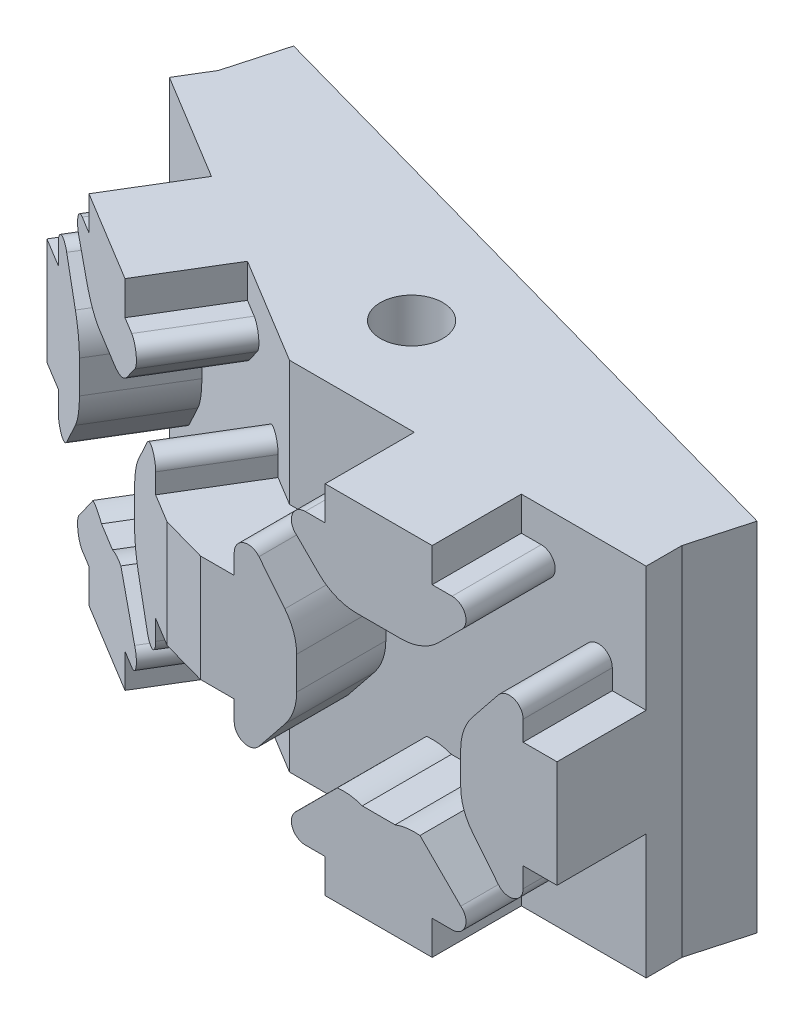
from build123d import *

# Parameters (mm, degrees)
SKIZZE1_W                       = 20
SKIZZE1_H                       = 20
AUFSATZ_LINEAR_AUSTRAGEN1_DEPTH = 2
AUFSATZ_LINEAR_AUSTRAGEN3_DEPTH = 5
VERRUNDUNG1_R                   = 3
VERRUNDUNG1_OF_SPIEGELN1_R      = 3
AUFSATZ_LINEAR_AUSTRAGEN4_REACH = 22.848
SKIZZE3_W                       = 37.447689889
SKIZZE3_H                       = 20
SKIZZE4_R                       = 1.75
SCHNITT_LINEAR_AUSTRAGEN1_DEPTH = 21
SKIZZE4_3_R                     = 2.9
SKIZZE4_3_R_2                   = 1.75
SCHNITT_LINEAR_AUSTRAGEN2_DEPTH = 16
AUFSATZ_LINEAR_AUSTRAGEN5_REACH = 27.254
SKIZZE5_W                       = 2.691263413
SKIZZE5_H                       = 6


with BuildPart() as part:
    # Skizze1 → Aufsatz-Linear austragen1 (new body)
    with BuildSketch(Plane.XY):
        with Locations((10, 10)):
            Rectangle(SKIZZE1_W, SKIZZE1_H)
    aufsatz_linear_austragen1 = extrude(amount=AUFSATZ_LINEAR_AUSTRAGEN1_DEPTH)

    # Skizze2 → Aufsatz-Linear austragen3 (add)
    with BuildSketch(Plane.XY.offset(2)):
        with BuildLine():
            Line((13, 18.1), (13, 20))
            Line((13, 20), (7, 20))
            Line((7, 20), (7, 18.1))
            Line((7, 18.1), (5.883086579, 18.1))
            ThreePointArc((5.883086579, 18.1), (5.147285539, 17.57883746), (5.394745881, 16.711786745))
            Line((5.394745881, 16.711786745), (7.506532626, 14.6))
            Line((7.506532626, 14.6), (9.080240322, 14.6))
            Line((9.080240322, 14.6), (10.919759678, 14.6))
            Line((10.919759678, 14.6), (12.493467374, 14.6))
            Line((12.493467374, 14.6), (14.605254119, 16.711786745))
            ThreePointArc((14.605254119, 16.711786745), (14.852714461, 17.57883746), (14.116913421, 18.1))
            Line((14.116913421, 18.1), (13, 18.1))
        make_face()
        with BuildLine():
            Line((1.9, 13), (0, 13))
            Line((0, 13), (0, 7))
            Line((0, 7), (1.9, 7))
            Line((1.9, 7), (1.9, 5.883086579))
            ThreePointArc((1.9, 5.883086579), (2.42116254, 5.147285539), (3.288213255, 5.394745881))
            Line((3.288213255, 5.394745881), (4.739281749, 7.20200687))
            ThreePointArc((4.739281749, 7.20200687), (5.230003997, 8.08471163), (5.4, 9.080240322))
            Line((5.4, 9.080240322), (5.4, 10.919759678))
            ThreePointArc((5.4, 10.919759678), (5.230003997, 11.91528837), (4.739281749, 12.79799313))
            Line((4.739281749, 12.79799313), (3.288213255, 14.605254119))
            ThreePointArc((3.288213255, 14.605254119), (2.42116254, 14.852714461), (1.9, 14.116913421))
            Line((1.9, 14.116913421), (1.9, 13))
        make_face()
        with BuildLine():
            Line((7, 0), (13, 0))
            Line((13, 0), (13, 1.9))
            Line((13, 1.9), (14.116913421, 1.9))
            ThreePointArc((14.116913421, 1.9), (14.852714461, 2.42116254), (14.605254119, 3.288213255))
            Line((14.605254119, 3.288213255), (12.315477065, 5.577990309))
            ThreePointArc((12.315477065, 5.577990309), (11.607035992, 5.571977263), (10.919759678, 5.4))
            Line((10.919759678, 5.4), (9.080240322, 5.4))
            ThreePointArc((9.080240322, 5.4), (8.392964008, 5.571977263), (7.684522935, 5.577990309))
            Line((7.684522935, 5.577990309), (5.394745881, 3.288213255))
            ThreePointArc((5.394745881, 3.288213255), (5.147285539, 2.42116254), (5.883086579, 1.9))
            Line((5.883086579, 1.9), (7, 1.9))
            Line((7, 1.9), (7, 0))
        make_face()
        with BuildLine():
            Line((20, 7), (20, 13))
            Line((20, 13), (18.1, 13))
            Line((18.1, 13), (18.1, 14.116913421))
            ThreePointArc((18.1, 14.116913421), (17.57883746, 14.852714461), (16.711786745, 14.605254119))
            Line((16.711786745, 14.605254119), (15.260718251, 12.79799313))
            ThreePointArc((15.260718251, 12.79799313), (14.769996003, 11.91528837), (14.6, 10.919759678))
            Line((14.6, 10.919759678), (14.6, 9.080240322))
            ThreePointArc((14.6, 9.080240322), (14.769996003, 8.08471163), (15.260718251, 7.20200687))
            Line((15.260718251, 7.20200687), (16.711786745, 5.394745881))
            ThreePointArc((16.711786745, 5.394745881), (17.57883746, 5.147285539), (18.1, 5.883086579))
            Line((18.1, 5.883086579), (18.1, 7))
            Line((18.1, 7), (20, 7))
        make_face()
    aufsatz_linear_austragen3 = extrude(amount=AUFSATZ_LINEAR_AUSTRAGEN3_DEPTH)

    # Verrundung1
    verrundung1_edges = [part.edges().sort_by_distance(p)[0] for p in [
        (7.506532626, 14.6, 4.5),
        (12.493467374, 14.6, 4.5),
    ]]
    fillet(verrundung1_edges, radius=VERRUNDUNG1_R)

    # Spiegeln1: Aufsatz-Linear austragen1, Aufsatz-Linear austragen3 across plane
    add(aufsatz_linear_austragen1.mirror(Plane(origin=(0.518393786, 0, 0.144857975), x_dir=(-0.269126341, 0, 0.963104881), z_dir=(-0.963104881, 0, -0.269126341))))
    add(aufsatz_linear_austragen3.mirror(Plane(origin=(0.518393786, 0, 0.144857975), x_dir=(-0.269126341, 0, 0.963104881), z_dir=(-0.963104881, 0, -0.269126341))))

    # Verrundung1 of Spiegeln1
    verrundung1_of_spiegeln1_edges = [part.edges().sort_by_distance(p)[0] for p in [
        (-7.715135975, 14.6, 0.246515195),
        (-11.979673452, 14.6, -2.338680788),
    ]]
    fillet(verrundung1_of_spiegeln1_edges, radius=VERRUNDUNG1_OF_SPIEGELN1_R)

    # Skizze3 → Aufsatz-Linear austragen4 (add, up to next)
    with BuildSketch(Plane(origin=(2.36988033, 0, -8.480936141), x_dir=(-0.963104881, 0, -0.269126341), z_dir=(0.269126341, 0, -0.963104881)), mode=Mode.PRIVATE) as aufsatz_linear_austragen4_sk1:
        with Locations((-0.538252683, 10)):
            Rectangle(SKIZZE3_W, SKIZZE3_H)
    aufsatz_linear_austragen4_tool1 = extrude(aufsatz_linear_austragen4_sk1.sketch, amount=-AUFSATZ_LINEAR_AUSTRAGEN4_REACH, mode=Mode.PRIVATE) - part.part
    add(aufsatz_linear_austragen4_tool1.solids().sort_by_distance((2.888274, 10, -8.336078))[0])

    # Skizze4 → Schnitt-Linear austragen1 (cut, through all)
    with BuildSketch(Plane.XZ):
        with Locations((1.495339923, -3.351275437)):
            Circle(SKIZZE4_R)
    extrude(amount=-SCHNITT_LINEAR_AUSTRAGEN1_DEPTH, mode=Mode.SUBTRACT)

    # Skizze4_3 → Schnitt-Linear austragen2 (cut)
    with BuildSketch(Plane.XZ):
        with Locations((1.495339923, -3.351275437)):
            Circle(SKIZZE4_3_R)
        with Locations((1.495339923, -3.351275437)):
            Circle(SKIZZE4_3_R_2, mode=Mode.SUBTRACT)
    extrude(amount=-SCHNITT_LINEAR_AUSTRAGEN2_DEPTH, mode=Mode.SUBTRACT)

    # Skizze5 → Aufsatz-Linear austragen5 (add, up to next)
    with BuildSketch(Plane(origin=(-1.814378251, 0, 6.492997087), x_dir=(0.963104881, 0, 0.269126341), z_dir=(-0.269126341, 0, 0.963104881)), mode=Mode.PRIVATE) as aufsatz_linear_austragen5_sk1:
        with Locations((0.538252683, 10)):
            Rectangle(SKIZZE5_W, SKIZZE5_H)
    aufsatz_linear_austragen5_tool1 = extrude(aufsatz_linear_austragen5_sk1.sketch, amount=-AUFSATZ_LINEAR_AUSTRAGEN5_REACH, mode=Mode.PRIVATE) - part.part
    add(aufsatz_linear_austragen5_tool1.solids().sort_by_distance((-1.295984, 10, 6.637855))[0])


solid = part.part
